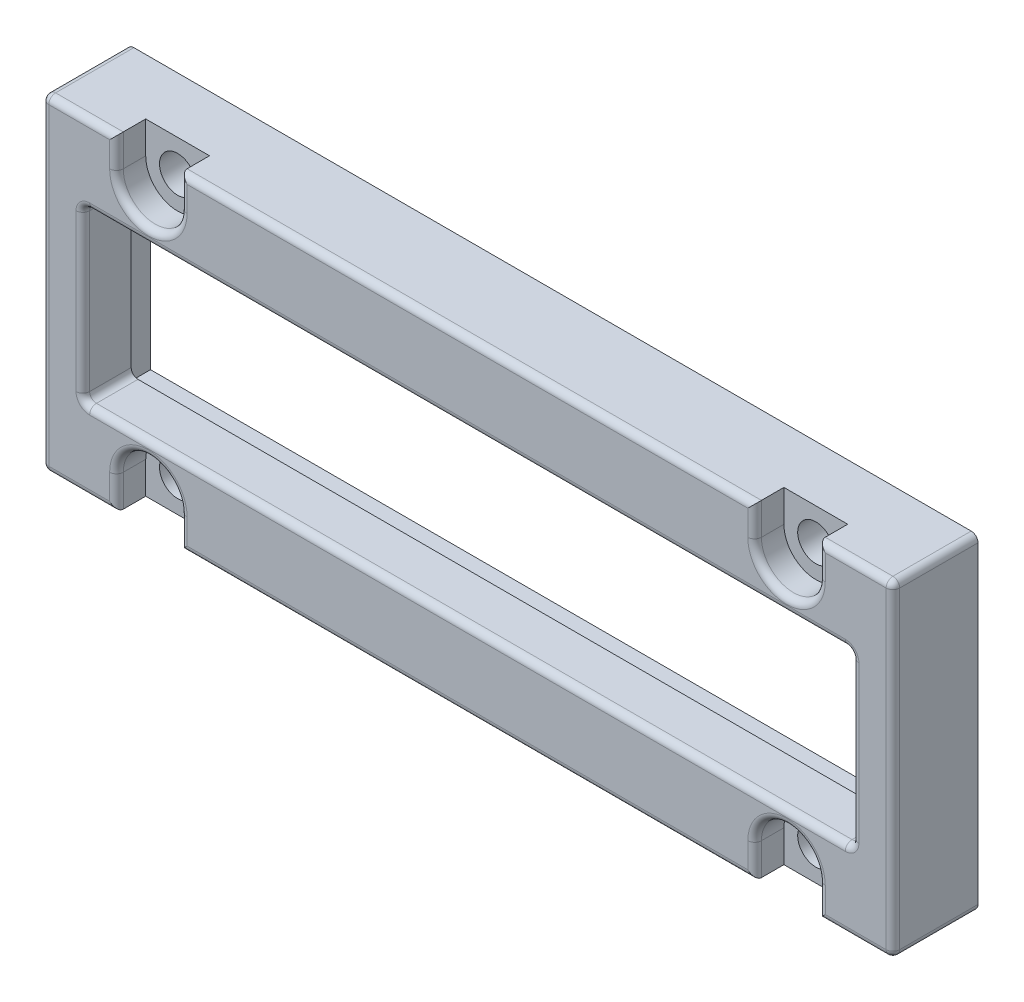
from build123d import *

# Parameters (mm, degrees)
SKETCH1_W                                      = 63.5
SKETCH1_H                                      = 24.384
BOSS_EXTRUDE1_DEPTH                            = 6.35
CBORE_FOR_2_SOCKET_HEAD_CAP_SCREW1_D           = 2.7051
CBORE_FOR_2_SOCKET_HEAD_CAP_SCREW1_CBORE_D     = 4.7625
CBORE_FOR_2_SOCKET_HEAD_CAP_SCREW1_CBORE_DEPTH = 2.1844
SKETCH4_W                                      = 57.404
SKETCH4_H                                      = 12.7
CUT_EXTRUDE1_DEPTH                             = 7.35
SKETCH5_W                                      = 4.7625
SKETCH5_H                                      = 2.3876
CUT_EXTRUDE2_DEPTH                             = 2.1844
SKETCH7_W                                      = 57.404
SKETCH7_H                                      = 12.7
CUT_EXTRUDE3_DEPTH                             = 2.7432
FILLET1_R                                      = 0.508
SKETCH11_W                                     = 60
SKETCH11_H                                     = 16
CUT_EXTRUDE6_DEPTH                             = 3.7432
BOSS_EXTRUDE2_REACH                            = 8.35


with BuildPart() as part:
    # Sketch1 → Boss-Extrude1 (new body)
    with BuildSketch(Plane.XY):
        with Locations((137.237805359, -177.626597764)):
            Rectangle(SKETCH1_W, SKETCH1_H)
    extrude(amount=BOSS_EXTRUDE1_DEPTH)

    # CBORE for #2 Socket Head Cap Screw1 (through all)
    with Locations(Plane.XY.offset(6.35)):
        with Locations((161.050305359, -187.430997764), (113.425305359, -187.430997764), (161.050305359, -167.822197764), (113.425305359, -167.822197764)):
            CounterBoreHole(CBORE_FOR_2_SOCKET_HEAD_CAP_SCREW1_D / 2, CBORE_FOR_2_SOCKET_HEAD_CAP_SCREW1_CBORE_D / 2, CBORE_FOR_2_SOCKET_HEAD_CAP_SCREW1_CBORE_DEPTH)

    # Sketch4 → Cut-Extrude1 (cut, through all)
    with BuildSketch(Plane.XY.offset(6.35)):
        with Locations((137.237805359, -177.626597764)):
            Rectangle(SKETCH4_W, SKETCH4_H)
    extrude(amount=-CUT_EXTRUDE1_DEPTH, mode=Mode.SUBTRACT)

    # Sketch5 → Cut-Extrude2 (cut)
    with BuildSketch(Plane.XY.offset(6.35)):
        with Locations((113.425305359, -166.628397764)):
            Rectangle(SKETCH5_W, SKETCH5_H)
        with Locations((161.050305359, -166.628397764)):
            Rectangle(SKETCH5_W, SKETCH5_H)
        with Locations((113.425305359, -188.624797764)):
            Rectangle(SKETCH5_W, SKETCH5_H)
        with Locations((161.050305359, -188.624797764)):
            Rectangle(SKETCH5_W, SKETCH5_H)
    extrude(amount=-CUT_EXTRUDE2_DEPTH, mode=Mode.SUBTRACT)

    # Sketch7 → Cut-Extrude3 (cut)
    with BuildSketch(Plane(origin=(0, 0, 0), x_dir=(-1, 0, 0), z_dir=(0, 0, -1))):
        with BuildLine():
            Line((-163.431555359, -167.822197764), (-163.431555359, -166.704597764))
            Line((-163.431555359, -166.704597764), (-167.717805359, -166.704597764))
            Line((-167.717805359, -166.704597764), (-167.717805359, -188.548597764))
            Line((-167.717805359, -188.548597764), (-163.431555359, -188.548597764))
            Line((-163.431555359, -188.548597764), (-163.431555359, -187.430997764))
            ThreePointArc((-163.431555359, -187.430997764), (-161.050305359, -185.049747764), (-158.669055359, -187.430997764))
            Line((-158.669055359, -187.430997764), (-158.669055359, -188.548597764))
            Line((-158.669055359, -188.548597764), (-115.806555359, -188.548597764))
            Line((-115.806555359, -188.548597764), (-115.806555359, -187.430997764))
            ThreePointArc((-115.806555359, -187.430997764), (-113.425305359, -185.049747764), (-111.044055359, -187.430997764))
            Line((-111.044055359, -187.430997764), (-111.044055359, -188.548597764))
            Line((-111.044055359, -188.548597764), (-106.757805359, -188.548597764))
            Line((-106.757805359, -188.548597764), (-106.757805359, -166.704597764))
            Line((-106.757805359, -166.704597764), (-111.044055359, -166.704597764))
            Line((-111.044055359, -166.704597764), (-111.044055359, -167.822197764))
            ThreePointArc((-111.044055359, -167.822197764), (-113.425305359, -170.203447764), (-115.806555359, -167.822197764))
            Line((-115.806555359, -167.822197764), (-115.806555359, -166.704597764))
            Line((-115.806555359, -166.704597764), (-158.669055359, -166.704597764))
            Line((-158.669055359, -166.704597764), (-158.669055359, -167.822197764))
            ThreePointArc((-158.669055359, -167.822197764), (-161.050305359, -170.203447764), (-163.431555359, -167.822197764))
        make_face()
        with Locations((-137.237805359, -177.626597764)):
            Rectangle(SKETCH7_W, SKETCH7_H, mode=Mode.SUBTRACT)
    extrude(amount=-CUT_EXTRUDE3_DEPTH, mode=Mode.SUBTRACT)

    # Fillet1
    fillet1_edges = [part.edges().sort_by_distance(p)[0] for p in [
        (105.487805359, -177.626597764, 6.35),
        (166.209680359, -189.818597764, 6.35),
        (158.669055359, -188.624797764, 6.35),
        (163.431555359, -188.624797764, 6.35),
        (108.265930359, -189.818597764, 6.35),
        (108.535805359, -171.276597764, 4.5466),
        (165.939805359, -171.276597764, 4.5466),
        (108.535805359, -183.976597764, 4.5466),
        (165.939805359, -183.976597764, 4.5466),
        (106.757805359, -166.704597764, 1.3716),
        (111.044055359, -166.704597764, 1.3716),
        (115.806555359, -166.704597764, 1.3716),
        (113.425305359, -185.049747764, 6.35),
        (161.050305359, -185.049747764, 6.35),
        (168.987805359, -177.626597764, 6.35),
        (165.939805359, -177.626597764, 6.35),
        (137.237805359, -171.276597764, 6.35),
        (108.535805359, -177.626597764, 6.35),
        (137.237805359, -183.976597764, 6.35),
        (113.425305359, -170.203447764, 6.35),
        (108.265930359, -165.434597764, 6.35),
        (115.806555359, -166.628397764, 6.35),
        (111.044055359, -166.628397764, 6.35),
        (166.209680359, -165.434597764, 6.35),
        (168.987805359, -189.818597764, 3.175),
        (105.487805359, -189.818597764, 3.175),
        (161.050305359, -170.203447764, 6.35),
        (105.487805359, -165.434597764, 3.175),
        (168.987805359, -165.434597764, 3.175),
        (137.237805359, -165.434597764, 6.35),
        (163.431555359, -166.628397764, 6.35),
        (158.669055359, -166.628397764, 6.35),
        (137.237805359, -189.818597764, 6.35),
        (115.806555359, -188.624797764, 6.35),
        (111.044055359, -188.624797764, 6.35),
    ]]
    fillet(fillet1_edges, radius=FILLET1_R)

    # Sketch11 → Cut-Extrude6 (cut, through all)
    with BuildSketch(Plane(origin=(0, 0, 2.7432), x_dir=(-1, 0, 0), z_dir=(0, 0, -1))):
        with Locations((-137.237805359, -177.626597764)):
            Rectangle(SKETCH11_W, SKETCH11_H)
    extrude(amount=CUT_EXTRUDE6_DEPTH, mode=Mode.SUBTRACT)

    # Sketch10 → Boss-Extrude2 (add, up to next)
    with BuildSketch(Plane(origin=(0, 0, 0), x_dir=(-1, 0, 0), z_dir=(0, 0, -1)), mode=Mode.PRIVATE) as boss_extrude2_sk1:
        with BuildLine():
            ThreePointArc((-158.669055359, -167.822197764), (-158.885762757, -168.814723274), (-159.496441722, -169.626597764))
            Line((-159.496441722, -169.626597764), (-114.979168996, -169.626597764))
            ThreePointArc((-114.979168996, -169.626597764), (-115.58984796, -168.814723274), (-115.806555359, -167.822197764))
            Line((-115.806555359, -167.822197764), (-115.806555359, -167.212597764))
            ThreePointArc((-115.806555359, -167.212597764), (-115.955345114, -166.853387519), (-116.314555359, -166.704597764))
            Line((-116.314555359, -166.704597764), (-158.669055359, -166.704597764))
            Line((-158.669055359, -166.704597764), (-158.669055359, -167.822197764))
        make_face()
    boss_extrude2_tool1 = extrude(boss_extrude2_sk1.sketch, amount=-BOSS_EXTRUDE2_REACH, mode=Mode.PRIVATE) - part.part
    add(boss_extrude2_tool1.solids().sort_by_distance((137.247168, -168.173633, 0))[0])
    # Sketch10 → Boss-Extrude2 (add, up to next)
    with BuildSketch(Plane(origin=(0, 0, 0), x_dir=(-1, 0, 0), z_dir=(0, 0, -1)), mode=Mode.PRIVATE) as boss_extrude2_sk2:
        with BuildLine():
            Line((-107.237805359, -185.626597764), (-111.871441722, -185.626597764))
            ThreePointArc((-111.871441722, -185.626597764), (-111.260762757, -186.438472254), (-111.044055359, -187.430997764))
            Line((-111.044055359, -187.430997764), (-111.044055359, -188.548597764))
            Line((-111.044055359, -188.548597764), (-106.757805359, -188.548597764))
            Line((-106.757805359, -188.548597764), (-106.757805359, -167.212597764))
            ThreePointArc((-106.757805359, -167.212597764), (-106.906595114, -166.853387519), (-107.265805359, -166.704597764))
            Line((-107.265805359, -166.704597764), (-110.536055359, -166.704597764))
            ThreePointArc((-110.536055359, -166.704597764), (-110.895265604, -166.853387519), (-111.044055359, -167.212597764))
            Line((-111.044055359, -167.212597764), (-111.044055359, -167.822197764))
            ThreePointArc((-111.044055359, -167.822197764), (-111.260762757, -168.814723274), (-111.871441722, -169.626597764))
            Line((-111.871441722, -169.626597764), (-107.237805359, -169.626597764))
            Line((-107.237805359, -169.626597764), (-107.237805359, -185.626597764))
        make_face()
    boss_extrude2_tool2 = extrude(boss_extrude2_sk2.sketch, amount=-BOSS_EXTRUDE2_REACH, mode=Mode.PRIVATE) - part.part
    add(boss_extrude2_tool2.solids().sort_by_distance((111.056834, -186.344963, 0))[0])
    # Sketch10 → Boss-Extrude2 (add, up to next)
    with BuildSketch(Plane(origin=(0, 0, 0), x_dir=(-1, 0, 0), z_dir=(0, 0, -1)), mode=Mode.PRIVATE) as boss_extrude2_sk3:
        with BuildLine():
            Line((-114.979168996, -185.626597764), (-159.496441722, -185.626597764))
            ThreePointArc((-159.496441722, -185.626597764), (-158.885762757, -186.438472254), (-158.669055359, -187.430997764))
            Line((-158.669055359, -187.430997764), (-158.669055359, -188.548597764))
            Line((-158.669055359, -188.548597764), (-115.806555359, -188.548597764))
            Line((-115.806555359, -188.548597764), (-115.806555359, -187.430997764))
            ThreePointArc((-115.806555359, -187.430997764), (-115.58984796, -186.438472254), (-114.979168996, -185.626597764))
        make_face()
    boss_extrude2_tool3 = extrude(boss_extrude2_sk3.sketch, amount=-BOSS_EXTRUDE2_REACH, mode=Mode.PRIVATE) - part.part
    add(boss_extrude2_tool3.solids().sort_by_distance((137.237805, -187.080157, 0))[0])
    # Sketch10 → Boss-Extrude2 (add, up to next)
    with BuildSketch(Plane(origin=(0, 0, 0), x_dir=(-1, 0, 0), z_dir=(0, 0, -1)), mode=Mode.PRIVATE) as boss_extrude2_sk4:
        with BuildLine():
            Line((-162.604168996, -185.626597764), (-167.237805359, -185.626597764))
            Line((-167.237805359, -185.626597764), (-167.237805359, -169.626597764))
            Line((-167.237805359, -169.626597764), (-162.604168996, -169.626597764))
            ThreePointArc((-162.604168996, -169.626597764), (-163.21484796, -168.814723274), (-163.431555359, -167.822197764))
            Line((-163.431555359, -167.822197764), (-163.431555359, -166.704597764))
            Line((-163.431555359, -166.704597764), (-167.717805359, -166.704597764))
            Line((-167.717805359, -166.704597764), (-167.717805359, -188.548597764))
            Line((-167.717805359, -188.548597764), (-163.431555359, -188.548597764))
            Line((-163.431555359, -188.548597764), (-163.431555359, -187.430997764))
            ThreePointArc((-163.431555359, -187.430997764), (-163.21484796, -186.438472254), (-162.604168996, -185.626597764))
        make_face()
    boss_extrude2_tool4 = extrude(boss_extrude2_sk4.sketch, amount=-BOSS_EXTRUDE2_REACH, mode=Mode.PRIVATE) - part.part
    add(boss_extrude2_tool4.solids().sort_by_distance((164.920987, -185.850943, 0))[0])


solid = part.part
